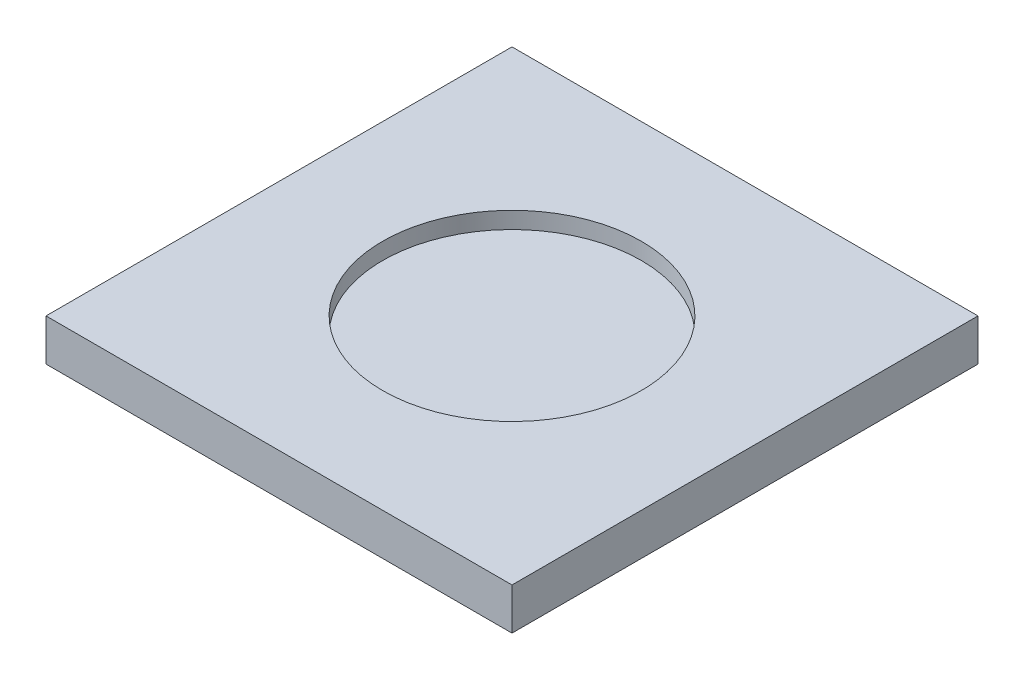
from build123d import *

# Parameters (mm, degrees)
SKETCH1_W           = 55.833333333
SKETCH1_H           = 55.833333333
BOSS_EXTRUDE1_DEPTH = 5
SKETCH2_R           = 15.5
CUT_EXTRUDE1_DEPTH  = 2


with BuildPart() as part:
    # Sketch1 → Boss-Extrude1 (new body)
    with BuildSketch(Plane(origin=(0, 0, 0), x_dir=(1, 0, 0), z_dir=(0, 1, 0))):
        with Locations((-16.232587065, -0.782338308)):
            Rectangle(SKETCH1_W, SKETCH1_H)
    extrude(amount=BOSS_EXTRUDE1_DEPTH)

    # Sketch2 → Cut-Extrude1 (cut)
    with BuildSketch(Plane(origin=(0, 5, 0), x_dir=(1, 0, 0), z_dir=(0, 1, 0))):
        with Locations((-16.232587065, -0.782338308)):
            Circle(SKETCH2_R)
    extrude(amount=-CUT_EXTRUDE1_DEPTH, mode=Mode.SUBTRACT)


solid = part.part
